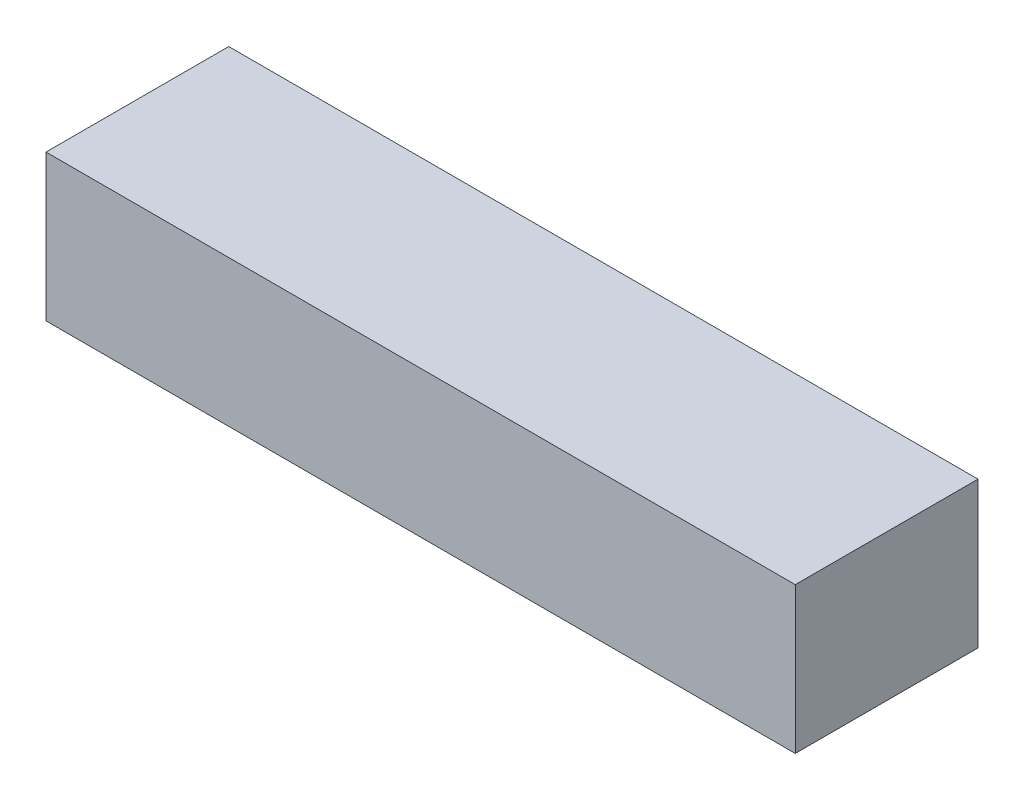
from build123d import *

# Parameters (mm, degrees)
SKETCH1_W           = 130.175
SKETCH1_H           = 31.75
BOSS_EXTRUDE1_DEPTH = 25.4


with BuildPart() as part:
    # Sketch1 → Boss-Extrude1 (new body)
    with BuildSketch(Plane(origin=(0, 0, 0), x_dir=(1, 0, 0), z_dir=(0, 1, 0))):
        Rectangle(SKETCH1_W, SKETCH1_H)
    extrude(amount=BOSS_EXTRUDE1_DEPTH)


solid = part.part
